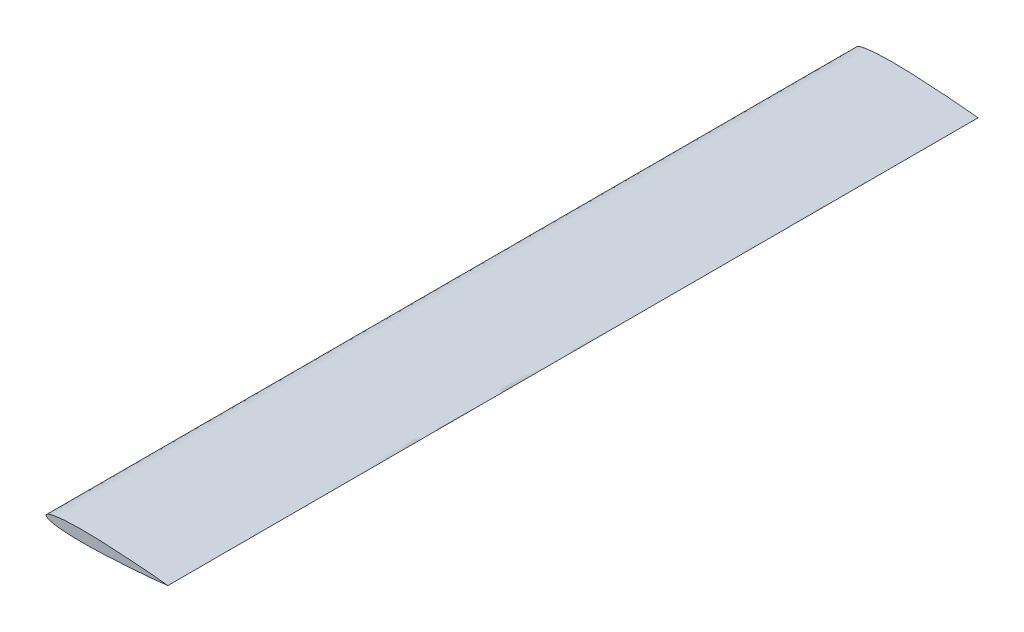
from build123d import *

# Parameters (mm, degrees)
BOSS_EXTRUDE1_DEPTH = 1330


with BuildPart() as part:
    # Sketch1 → Boss-Extrude1 (new body)
    with BuildSketch(Plane.XY):
        with BuildLine():
            add(Edge.make_bspline(
                [(200, 0), (200, 0.038208179), (198.173049044, 0.19022505), (196.299321828, 0.507442706), (191.74790241, 0.993763141), (186.155835511, 1.597424839), (178.869410335, 2.305816721), (170.314746269, 3.087573551), (160.529272094, 3.92759907), (149.717754924, 4.801312359), (138.052566355, 5.673814465), (125.737106614, 6.519252588), (112.981210062, 7.298723884), (100.003286779, 7.979219047), (87.024927754, 8.520286322), (76.308652125, 8.832851856), (67.90234379, 8.976442267), (61.786774306, 9.027401842), (55.834416019, 9.020283411), (50.070727516, 8.943660593), (44.520838848, 8.809162096), (39.208974434, 8.606040244), (34.157459026, 8.341691171), (29.387255791, 8.009952664), (24.918591532, 7.616438025), (20.772045952, 7.157701782), (16.964902636, 6.642489305), (13.512047693, 6.08408238), (10.427861272, 5.484982095), (7.722362477, 4.847264677), (5.408363455, 4.149453708), (3.490886808, 3.378624359), (1.987477258, 2.528120237), (0.906342383, 1.640006236), (0.231166119, 0.826014489), (-0.094593139, 0), (0.231166119, -0.826014489), (0.906342383, -1.640006236), (1.987477258, -2.528120237), (3.490886808, -3.378624359), (5.408363455, -4.149453708), (7.722362477, -4.847264677), (10.427861272, -5.484982095), (13.512047693, -6.08408238), (16.964902636, -6.642489305), (20.772045952, -7.157701782), (24.918591532, -7.616438025), (29.387255791, -8.009952664), (34.157459026, -8.341691171), (39.208974434, -8.606040244), (44.520838848, -8.809162096), (50.070727516, -8.943660593), (55.834416019, -9.020283411), (61.786774306, -9.027401842), (67.90234379, -8.976442267), (76.308652125, -8.832851856), (87.024927754, -8.520286322), (100.003286779, -7.979219047), (112.981210062, -7.298723884), (125.737106614, -6.519252588), (138.052566355, -5.673814465), (149.717754924, -4.801312359), (160.529272094, -3.92759907), (170.314746269, -3.087573551), (178.869410335, -2.305816721), (186.155835511, -1.597424839), (191.74790241, -0.993763141), (196.299321828, -0.507442706), (198.173049044, -0.19022505), (200, -0.038208179), (200, 0)],
                knots=[0, 0, 0, 0, 0.002133427, 0.008488156, 0.018944487, 0.033319114, 0.051356294, 0.072756093, 0.097140817, 0.124097489, 0.153162557, 0.183833918, 0.215589374, 0.247878195, 0.280150868, 0.311860397, 0.327332943, 0.342462846, 0.357187102, 0.371448118, 0.385183441, 0.398331273, 0.410844637, 0.422672607, 0.433769314, 0.444090175, 0.453589412, 0.46224044, 0.470010037, 0.476870985, 0.482833353, 0.487908551, 0.492155164, 0.495592273, 0.498196359, 0.5, 0.501803641, 0.504407727, 0.507844836, 0.512091449, 0.517166647, 0.523129015, 0.529989963, 0.53775956, 0.546410588, 0.555909825, 0.566230686, 0.577327393, 0.589155363, 0.601668727, 0.614816559, 0.628551882, 0.642812898, 0.657537154, 0.672667057, 0.688139603, 0.719849132, 0.752121805, 0.784410626, 0.816166082, 0.846837443, 0.875902511, 0.902859183, 0.927243907, 0.948643706, 0.966680886, 0.981055513, 0.991511844, 0.997866573, 1, 1, 1, 1], degree=3))
        make_face()
    extrude(amount=BOSS_EXTRUDE1_DEPTH)


solid = part.part
